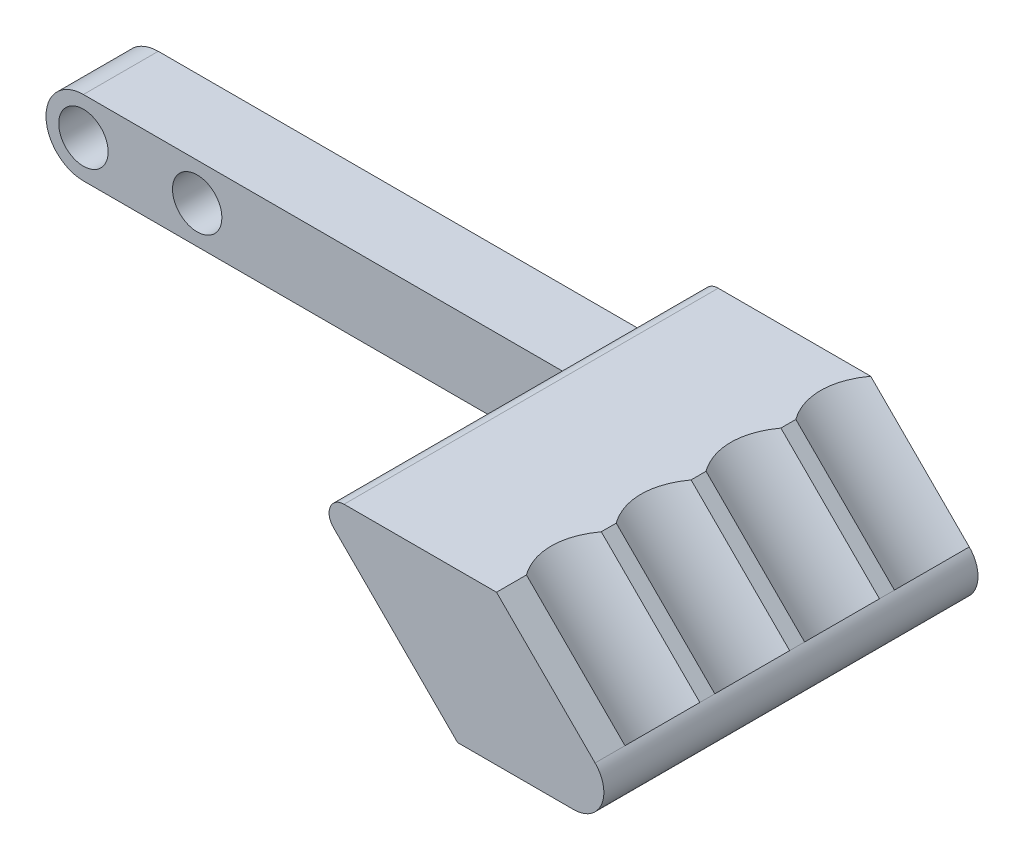
from build123d import *

# Parameters (mm, degrees)
SKETCH2_R           = 1.65
BOSS_EXTRUDE1_DEPTH = 5
FILLET1_R           = 2
FILLET2_R           = 1
FILLET3_R           = 1
SKETCH3_R           = 5.5
CUT_EXTRUDE1_DEPTH  = 34
BOSS_EXTRUDE2_DEPTH = 20
LPATTERN1_COUNT     = 4
LPATTERN1_PITCH     = 6


with BuildPart() as part:
    # Sketch2 → Boss-Extrude1 (new body)
    with BuildSketch(Plane.XY):
        with BuildLine():
            Line((40, 2.5), (0, 2.5))
            ThreePointArc((0, 2.5), (-2.5, 0), (0, -2.5))
            Line((0, -2.5), (57.6, -2.5))
            Line((57.6, -2.5), (47.6, 7.5))
            Line((47.6, 7.5), (35, 7.5))
            Line((35, 7.5), (40, 2.5))
        make_face()
        with Locations((7.6, 0)):
            Circle(SKETCH2_R, mode=Mode.SUBTRACT)
        Circle(SKETCH2_R, mode=Mode.SUBTRACT)
    extrude(amount=BOSS_EXTRUDE1_DEPTH)

    # Fillet1
    fillet1_edges = [part.edges().sort_by_distance(p)[0] for p in [
        (57.6, -2.5, 2.5),
    ]]
    fillet(fillet1_edges, radius=FILLET1_R)

    # Fillet2
    fillet2_edges = [part.edges().sort_by_distance(p)[0] for p in [
        (40, 2.5, 2.5),
    ]]
    fillet(fillet2_edges, radius=FILLET2_R)

    # Fillet3
    fillet3_edges = [part.edges().sort_by_distance(p)[0] for p in [
        (35, 7.5, 2.5),
    ]]
    fillet(fillet3_edges, radius=FILLET3_R)

    # Sketch3 → Cut-Extrude1 (cut)
    with BuildSketch(Plane(origin=(26.635786438, -26.635786438, 0), x_dir=(0, 0, -1), z_dir=(0.707106781, -0.707106781, 0))):
        with Locations((-2.5, 43.860563129)):
            Circle(SKETCH3_R)
    cut_extrude1 = extrude(amount=-CUT_EXTRUDE1_DEPTH, mode=Mode.SUBTRACT)

    # Sketch4 → Boss-Extrude2 (add)
    with BuildSketch(Plane.XY.offset(5)):
        with BuildLine():
            Line((37.414213562, 7.5), (47.6, 7.5))
            Line((47.6, 7.5), (54.185786438, 0.914213562))
            ThreePointArc((54.185786438, 0.914213562), (54.61933194, -1.265366865), (52.771572875, -2.5))
            Line((52.771572875, -2.5), (45, -2.5))
            Line((45, -2.5), (38.292893219, 4.207106781))
            Line((38.292893219, 4.207106781), (36.707106781, 5.792893219))
            ThreePointArc((36.707106781, 5.792893219), (36.49033403, 6.882683432), (37.414213562, 7.5))
        make_face()
    extrude(amount=BOSS_EXTRUDE2_DEPTH)

    # LPattern1: Cut-Extrude1 ×4
    with Locations(*[(0, 0, i * LPATTERN1_PITCH) for i in range(1, LPATTERN1_COUNT)]):
        add(cut_extrude1, mode=Mode.SUBTRACT)


solid = part.part
